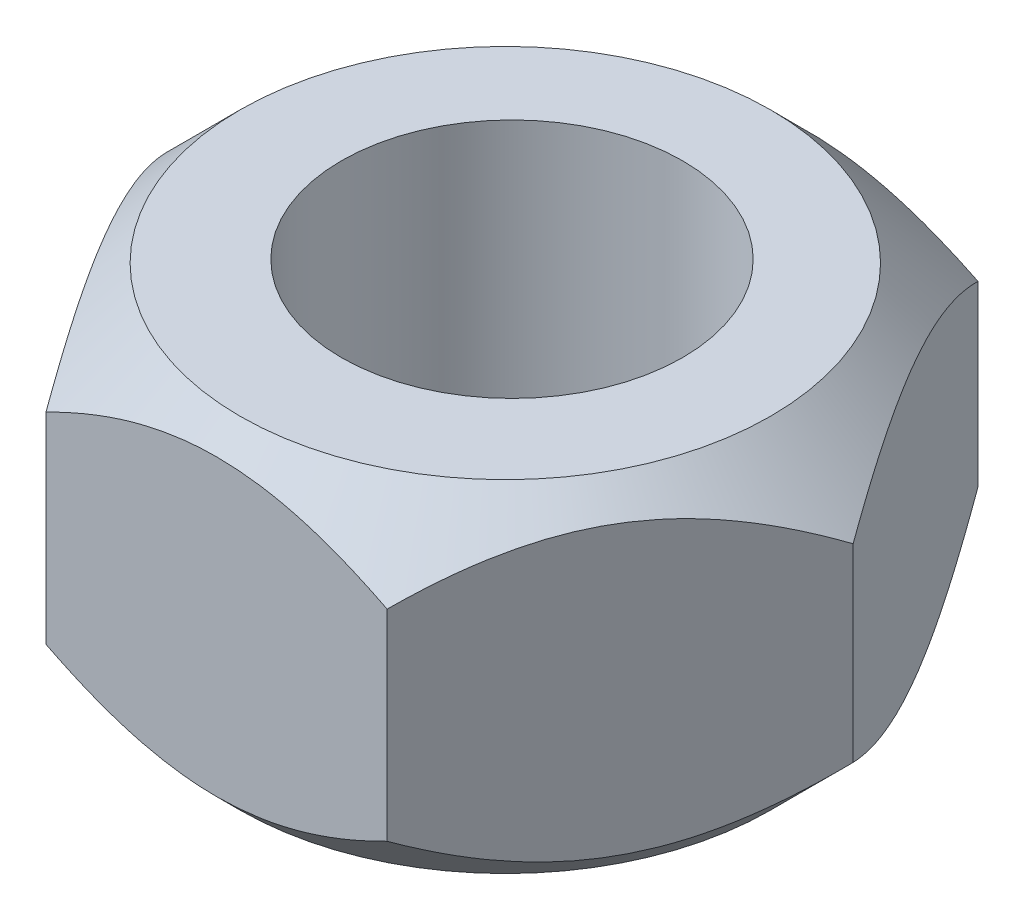
from build123d import *

# Parameters (mm, degrees)
SKETCH1_R           = 4.5
BOSS_EXTRUDE1_DEPTH = 4.5
SKETCH2_OUTSIDE_W   = 43.092
SKETCH2_OUTSIDE_H   = 40.68
SKETCH2_OUTSIDE_R   = 7
CUT_EXTRUDE2_DEPTH  = 9
CUT_EXTRUDE2_TAPER  = 45


with BuildPart() as part:
    # Sketch1 → Boss-Extrude1 (new body, symmetric)
    with BuildSketch(Plane(origin=(0, 0, 0), x_dir=(1, 0, 0), z_dir=(0, 1, 0))):
        Polygon((-4.5, -7.794228634), (4.5, -7.794228634), (9, 0), (4.5, 7.794228634), (-4.5, 7.794228634), (-9, 0), align=None)
        with Locations(Location((0, 0, 0), (0, 0, 270))):  # turned: the seam where the file's is
            Circle(SKETCH1_R, mode=Mode.SUBTRACT)
    extrude(amount=BOSS_EXTRUDE1_DEPTH, both=True)

    # Sketch2 outside → Cut-Extrude2 (cut)
    with BuildSketch(Plane(origin=(0, 4.5, 0), x_dir=(1, 0, 0), z_dir=(0, 1, 0))):
        Rectangle(SKETCH2_OUTSIDE_W, SKETCH2_OUTSIDE_H)
        with Locations((0, -0.176410187)):
            Circle(SKETCH2_OUTSIDE_R, mode=Mode.SUBTRACT)
    cut_extrude2 = extrude(amount=-CUT_EXTRUDE2_DEPTH, taper=CUT_EXTRUDE2_TAPER, mode=Mode.SUBTRACT)

    # Mirror4: Cut-Extrude2 across plane
    add(cut_extrude2.mirror(Plane.ZX), mode=Mode.SUBTRACT)


solid = part.part
